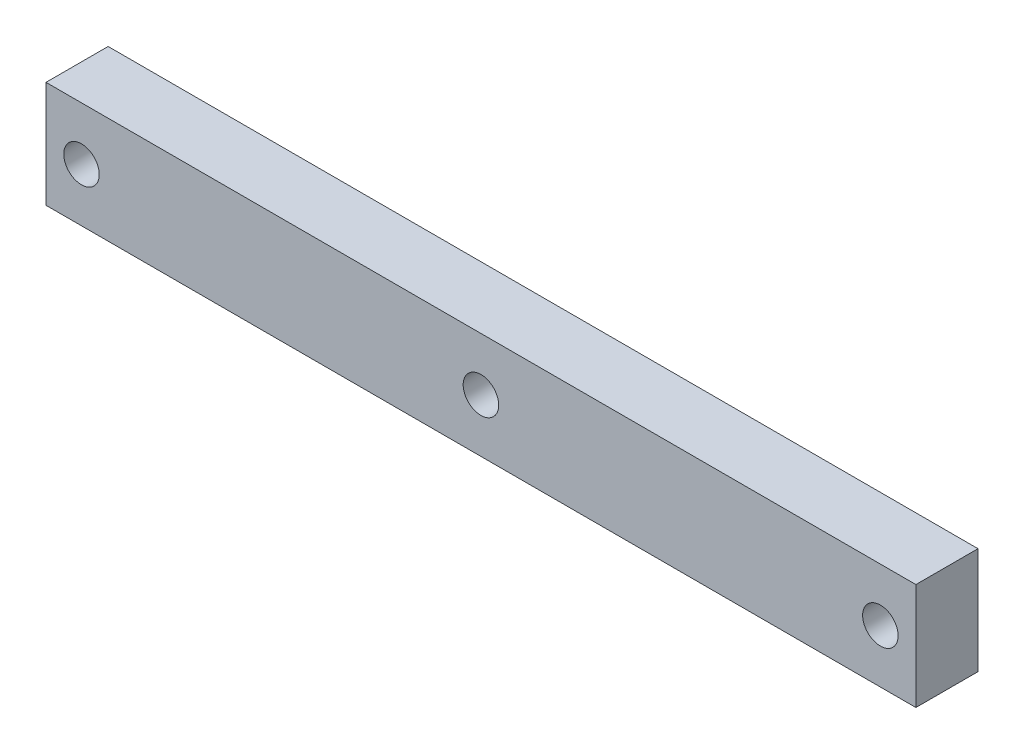
from build123d import *

# Parameters (mm, degrees)
SKETCH1_W           = 98
SKETCH1_H           = 12
SKETCH1_R           = 2
BOSS_EXTRUDE1_DEPTH = 7


with BuildPart() as part:
    # Sketch1 → Boss-Extrude1 (new body)
    with BuildSketch(Plane.XY):
        Rectangle(SKETCH1_W, SKETCH1_H)
        Circle(SKETCH1_R, mode=Mode.SUBTRACT)
        with Locations((45, 0)):
            Circle(SKETCH1_R, mode=Mode.SUBTRACT)
        with Locations((-45, 0)):
            Circle(SKETCH1_R, mode=Mode.SUBTRACT)
    extrude(amount=BOSS_EXTRUDE1_DEPTH)


solid = part.part
